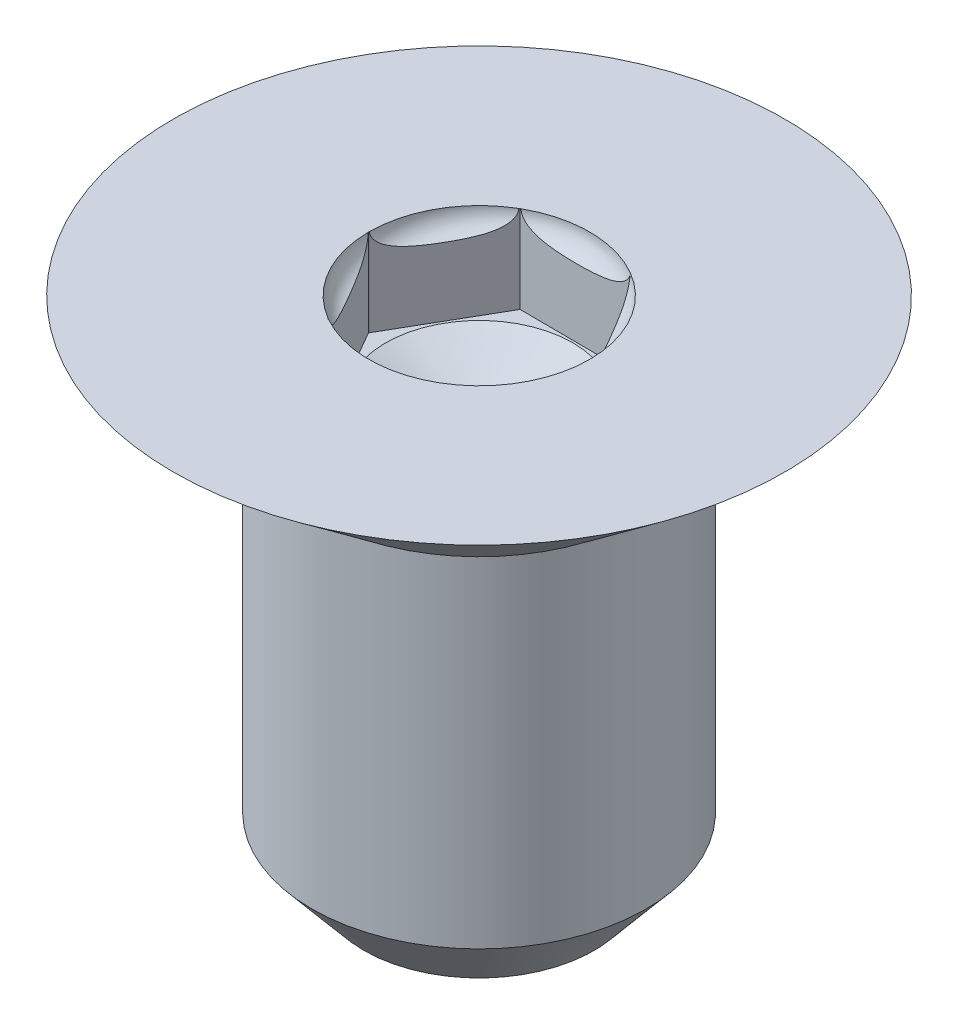
from build123d import *

# Parameters (mm, degrees)
CUT_EXTRUDE1_DEPTH = 1.0922
CUT_EXTRUDE2_DEPTH = 7.35


with BuildPart() as part:
    # Sketch1 → Revolve1 (revolve)
    with BuildSketch(Plane.XY):
        Polygon((-9.232559292, 19.989816719), (-5.422559292, 19.989816719), (-7.149759292, 18.643616719), (-7.149759292, 14.411514199), (-7.797290363, 13.639816719), (-9.232559292, 13.639816719), align=None)
    revolve(axis=Axis((-9.232559292, 19.989816719, 0), (0, -1, 0)))

    # Sketch2 → Cut-Extrude1 (cut)
    with BuildSketch(Plane(origin=(0, 19.989816719, 0), x_dir=(1, 0, 0), z_dir=(0, 1, 0))):
        Polygon((-9.926643575, 1.1938), (-8.548145113, 1.1938), (-7.851656024, 0.004194621), (-8.540905254, -1.189620065), (-9.919378278, -1.197994621), (-10.608627508, -0.004179935), align=None)
    extrude(amount=-CUT_EXTRUDE1_DEPTH, mode=Mode.SUBTRACT)

    # Sketch4 → Cut-Extrude2 (cut, through all)
    with BuildSketch(Plane(origin=(0, 19.989816719, 0), x_dir=(1, 0, 0), z_dir=(0, 1, 0))):
        Polygon((-13.85844337, 0), (-4.15558518, 0), (-6.419880254, 3.714859107), (-9.922461698, 4.192483849), (-13.787684149, 2.78614433), align=None)
    extrude(amount=-CUT_EXTRUDE2_DEPTH, mode=Mode.SUBTRACT)

    # Sketch5 → Cut-Revolve1 (revolve, cut)
    with BuildSketch(Plane(origin=(0, 0, 0), x_dir=(-1, 0, 0), z_dir=(0, 0, -1))):
        with BuildLine():
            Line((9.230162876, 18.529316719), (9.598462876, 18.529316719))
            Line((9.598462876, 18.529316719), (10.39700559, 18.897616719))
            Line((10.39700559, 18.897616719), (10.39700559, 19.741247113))
            ThreePointArc((10.39700559, 19.741247113), (10.546973564, 19.827359633), (10.606247963, 19.989816719))
            Line((10.606247963, 19.989816719), (10.353982568, 19.989816719))
            Line((10.353982568, 19.989816719), (9.230162876, 19.989816719))
            Line((9.230162876, 19.989816719), (9.230162876, 18.529316719))
        make_face()
    revolve(axis=Axis((-9.230162876, 18.897616719, 0), (0, 1, 0)), mode=Mode.SUBTRACT)

    # Mirror1: part across plane


with BuildPart() as part_1:
    add(part.part)
    add(part.part.mirror(Plane(origin=(-13.85844337, 13.639816719, 0), x_dir=(1, 0, 0), z_dir=(0, 0, 1))))


solid = part_1.part
